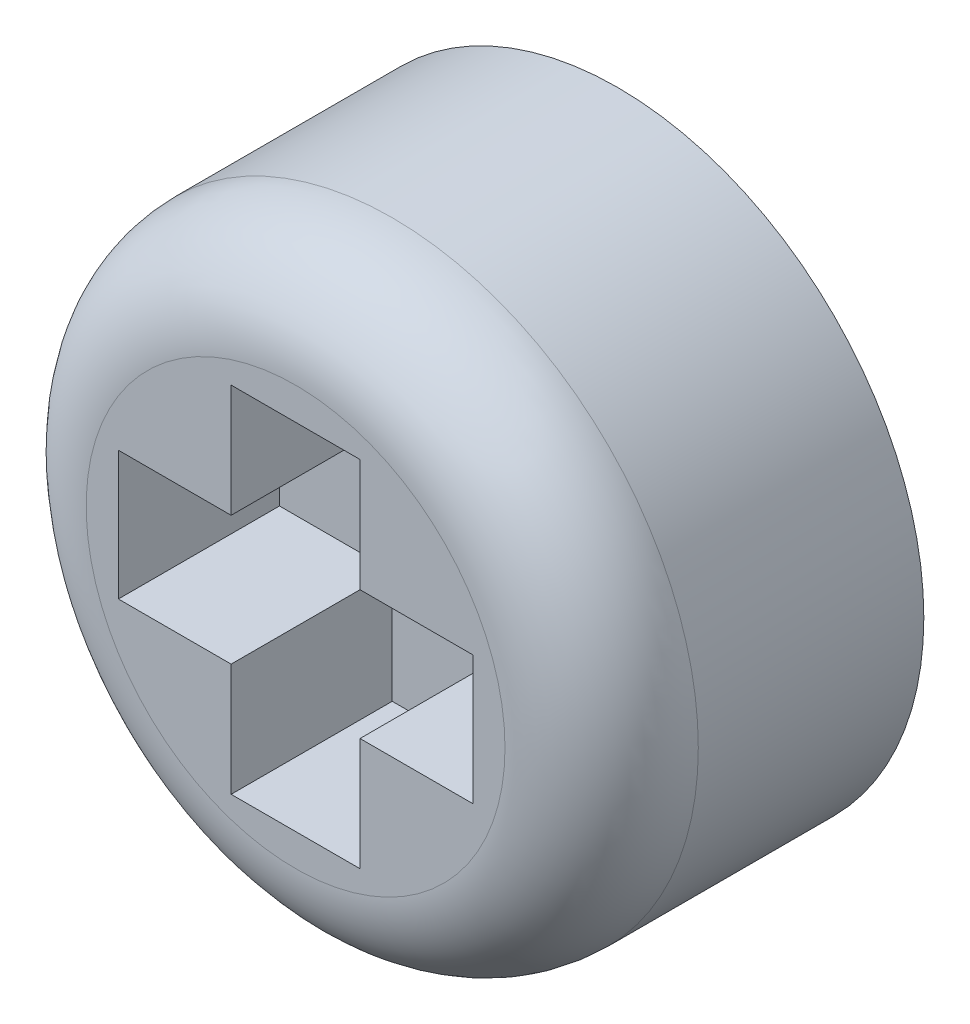
from build123d import *

# Parameters (mm, degrees)
SKETCH1_R           = 2.413
BOSS_EXTRUDE1_DEPTH = 2.54
CUT_EXTRUDE1_DEPTH  = 1.27
FILLET1_R           = 0.762


with BuildPart() as part:
    # Sketch1 → Boss-Extrude1 (new body)
    with BuildSketch(Plane.XY):
        Circle(SKETCH1_R)
    extrude(amount=BOSS_EXTRUDE1_DEPTH)

    # Sketch2 → Cut-Extrude1 (cut)
    with BuildSketch(Plane.XY.offset(2.54)):
        Polygon((-0.508, 0.508), (-0.508, 1.397), (0.508, 1.397), (0.508, 0.508), (1.397, 0.508), (1.397, -0.508), (0.508, -0.508), (0.508, -1.397), (-0.508, -1.397), (-0.508, -0.508), (-1.397, -0.508), (-1.397, 0.508), align=None)
    extrude(amount=-CUT_EXTRUDE1_DEPTH, mode=Mode.SUBTRACT)

    # Fillet1
    fillet1_edges = [part.edges().sort_by_distance(p)[0] for p in [
        (-2.413, 0, 2.54),
    ]]
    fillet(fillet1_edges, radius=FILLET1_R)


solid = part.part
